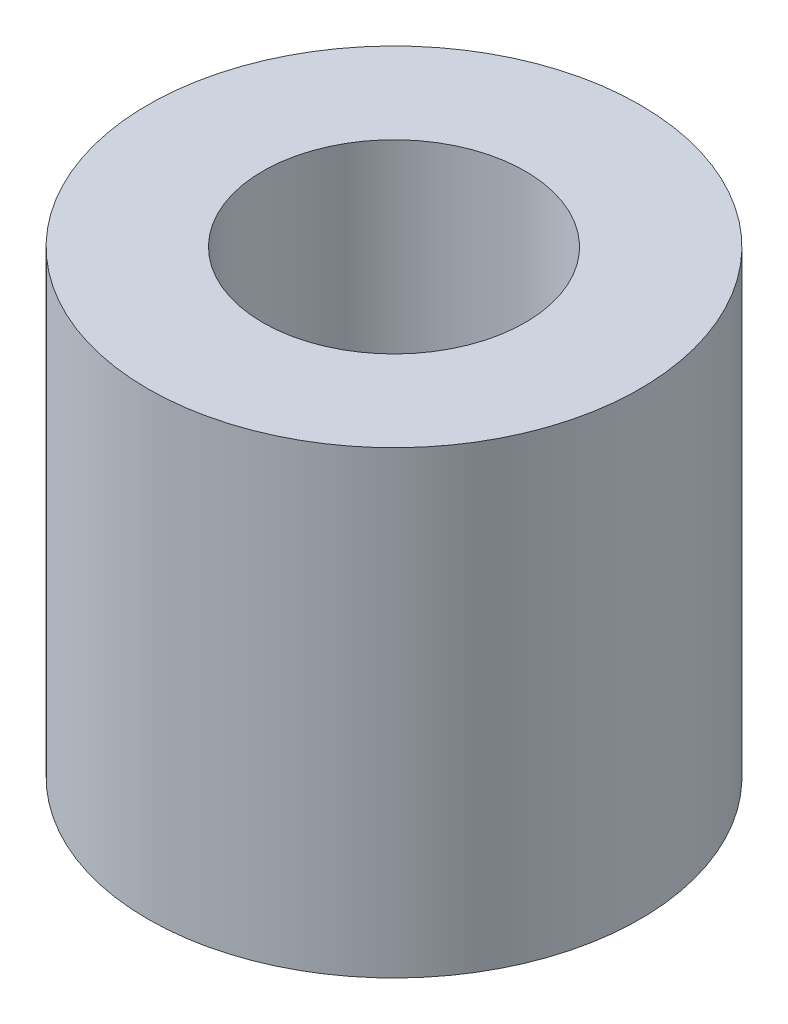
from build123d import *


with BuildPart() as part:
    # Sketch1 → Revolve1 (revolve)
    with BuildSketch(Plane.XY):
        Polygon((0, 0), (-7.5, 0), (-7.5, 14), (-4, 14), (-4, 4), (0, 1.690598923), align=None)
    revolve(axis=Axis((0, 19.509951269, 0), (0, -1, 0)))


solid = part.part
